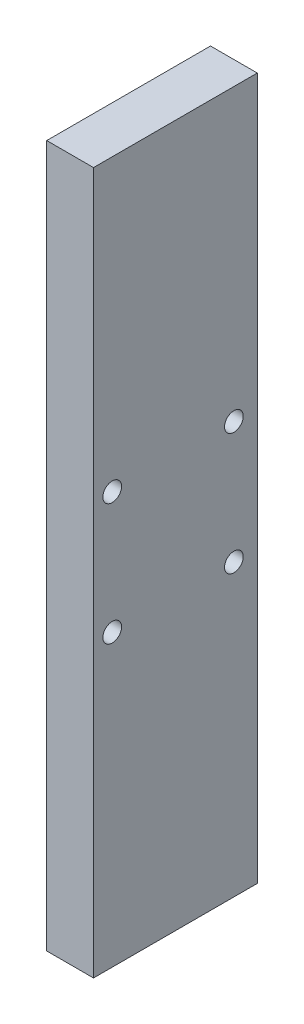
from build123d import *

# Parameters (mm, degrees)
SKETCH1_W           = 35
SKETCH1_H           = 150
BOSS_EXTRUDE1_DEPTH = 10
SKETCH2_R           = 2
CUT_EXTRUDE1_DEPTH  = 10


with BuildPart() as part:
    # Sketch1 → Boss-Extrude1 (new body)
    with BuildSketch(Plane(origin=(0, 0, 0), x_dir=(0, 0, -1), z_dir=(1, 0, 0))):
        with Locations((17.5, 75)):
            Rectangle(SKETCH1_W, SKETCH1_H)
    extrude(amount=BOSS_EXTRUDE1_DEPTH)

    # Sketch2 → Cut-Extrude1 (cut)
    with BuildSketch(Plane(origin=(10, 0, 0), x_dir=(0, 0, -1), z_dir=(1, 0, 0))):
        with Locations((4, 88)):
            Circle(SKETCH2_R)
        with Locations((30, 88)):
            Circle(SKETCH2_R)
        with Locations((30, 62)):
            Circle(SKETCH2_R)
        with Locations((4, 62)):
            Circle(SKETCH2_R)
    extrude(amount=-CUT_EXTRUDE1_DEPTH, mode=Mode.SUBTRACT)


solid = part.part
